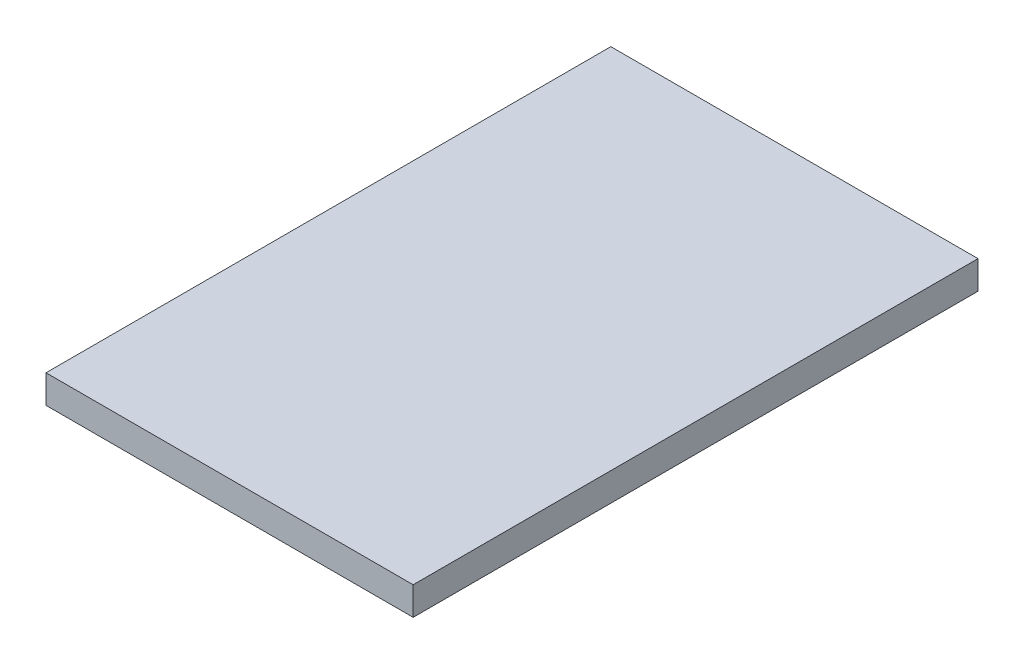
from build123d import *

# Parameters (mm, degrees)
SKETCH1_W           = 330.2
SKETCH1_H           = 508
BOSS_EXTRUDE1_DEPTH = 25.4


with BuildPart() as part:
    # Sketch1 → Boss-Extrude1 (new body)
    with BuildSketch(Plane(origin=(0, 0, 0), x_dir=(1, 0, 0), z_dir=(0, 1, 0))):
        with Locations((58.531016631, -24.295652174)):
            Rectangle(SKETCH1_W, SKETCH1_H)
    extrude(amount=BOSS_EXTRUDE1_DEPTH)


solid = part.part
